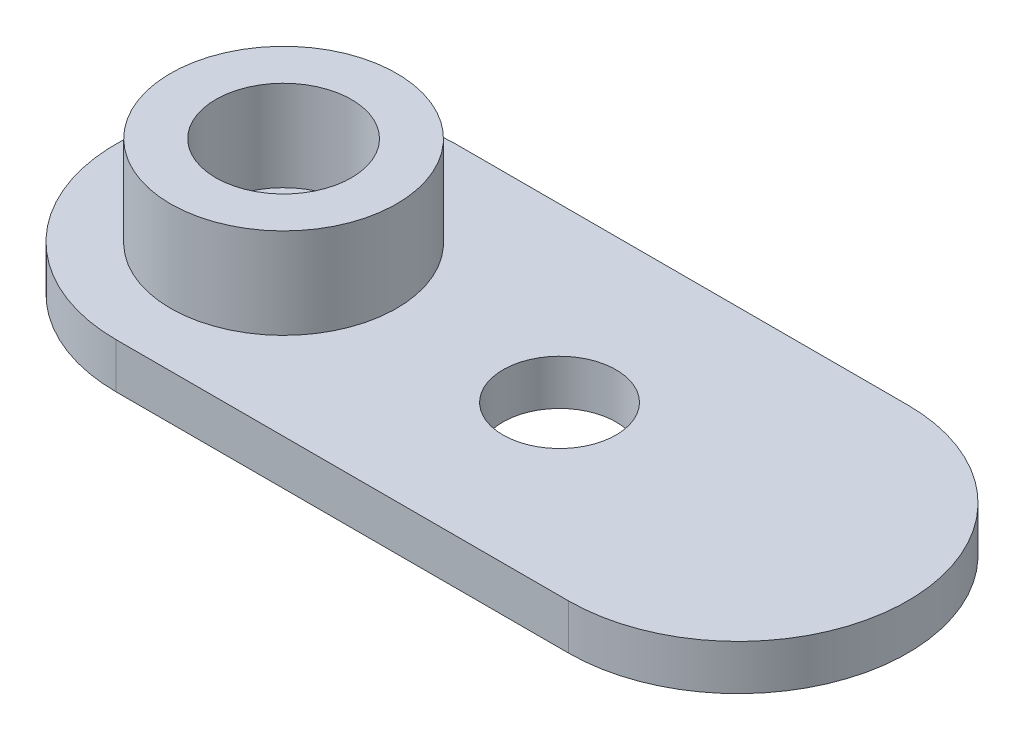
from build123d import *

# Parameters (mm, degrees)
BOSS_EXTRUDE1_DEPTH = 2
SKETCH2_R           = 5
BOSS_EXTRUDE3_DEPTH = 4
SKETCH5_R           = 3
CUT_EXTRUDE1_DEPTH  = 4
SKETCH6_R           = 1.5
CUT_EXTRUDE2_DEPTH  = 2
SKETCH7_R           = 2.5
CUT_EXTRUDE4_DEPTH  = 3


with BuildPart() as part:
    # Sketch1 → Boss-Extrude1 (new body)
    with BuildSketch(Plane(origin=(0, 0, 0), x_dir=(1, 0, 0), z_dir=(0, 1, 0))):
        with BuildLine():
            Line((0, 7.598649923), (20, 7.598649923))
            ThreePointArc((20, 7.598649923), (27.5, 0.098649923), (20, -7.401350077))
            Line((20, -7.401350077), (0, -7.401350077))
            ThreePointArc((0, -7.401350077), (-7.5, 0.098649923), (0, 7.598649923))
        make_face()
    extrude(amount=BOSS_EXTRUDE1_DEPTH)

    # Sketch2 → Boss-Extrude3 (add)
    with BuildSketch(Plane(origin=(0, 2, 0), x_dir=(1, 0, 0), z_dir=(0, 1, 0))):
        Circle(SKETCH2_R)
    extrude(amount=BOSS_EXTRUDE3_DEPTH)

    # Sketch5 → Cut-Extrude1 (cut)
    with BuildSketch(Plane(origin=(0, 6, 0), x_dir=(1, 0, 0), z_dir=(0, 1, 0))):
        Circle(SKETCH5_R)
    extrude(amount=-CUT_EXTRUDE1_DEPTH, mode=Mode.SUBTRACT)

    # Sketch6 → Cut-Extrude2 (cut)
    with BuildSketch(Plane(origin=(0, 2, 0), x_dir=(1, 0, 0), z_dir=(0, 1, 0))):
        Circle(SKETCH6_R)
    extrude(amount=-CUT_EXTRUDE2_DEPTH, mode=Mode.SUBTRACT)

    # Sketch7 → Cut-Extrude4 (cut, through all)
    with BuildSketch(Plane(origin=(0, 2, 0), x_dir=(1, 0, 0), z_dir=(0, 1, 0))):
        with Locations((12.2, 0)):
            Circle(SKETCH7_R)
    extrude(amount=-CUT_EXTRUDE4_DEPTH, mode=Mode.SUBTRACT)


solid = part.part
